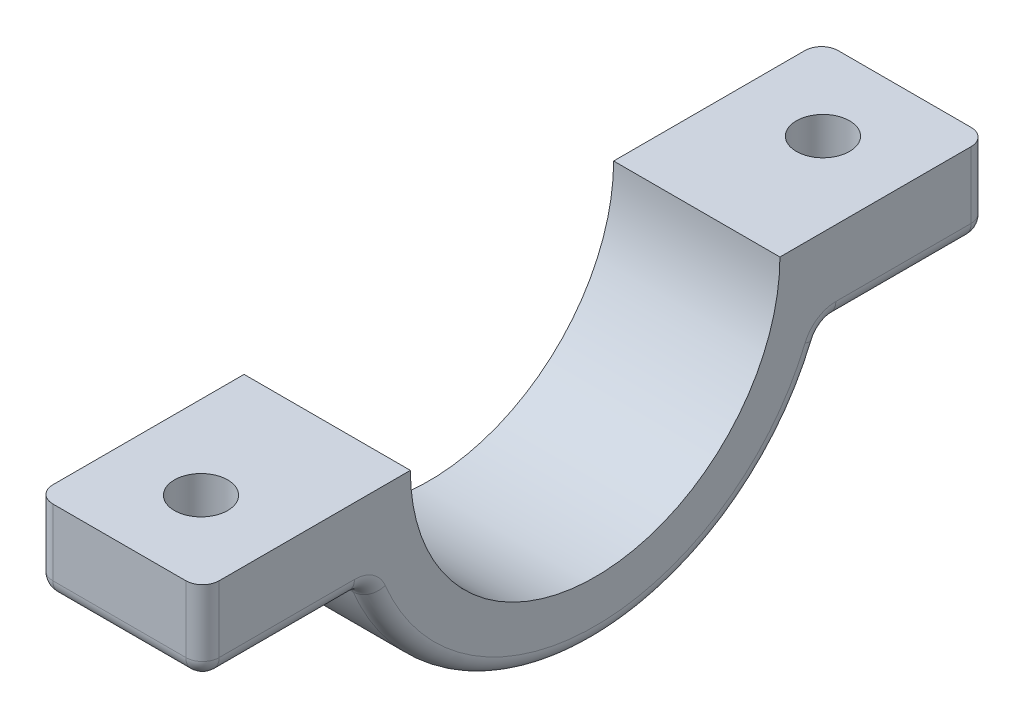
from build123d import *

# Parameters (mm, degrees)
CLAMP_EXTRUDE_DEPTH     = 10
HOLE_R                  = 1.6
HOLES_CUT_EXTRUDE_DEPTH = 6
FILLET1_R               = 1


with BuildPart() as part:
    # Sketch4 → Clamp Extrude (new body)
    with BuildSketch(Plane(origin=(0, 0, 0), x_dir=(0, 0, -1), z_dir=(1, 0, 0))):
        with BuildLine():
            Line((-23.6125, 0), (-11.1125, 0))
            ThreePointArc((-11.1125, 0), (0, -11.1125), (11.1125, 0))
            Line((11.1125, 0), (23.6125, 0))
            Line((23.6125, 0), (23.6125, -5))
            Line((23.6125, -5), (13.789947652, -5))
            ThreePointArc((13.789947652, -5), (0, -14.668423782), (-13.789947652, -5))
            Line((-13.789947652, -5), (-23.6125, -5))
            Line((-23.6125, -5), (-23.6125, 0))
        make_face()
    extrude(amount=CLAMP_EXTRUDE_DEPTH)

    # Hole → Holes Cut-Extrude (cut, through all)
    with BuildSketch(Plane.XZ.offset(5)):
        with Locations((5, 18.701223826)):
            Circle(HOLE_R)
        with Locations((5, -18.701223826)):
            Circle(HOLE_R)
    extrude(amount=-HOLES_CUT_EXTRUDE_DEPTH, mode=Mode.SUBTRACT)

    # Fillet1
    fillet1_edges = [part.edges().sort_by_distance(p)[0] for p in [
        (0, -2.5, -23.6125),
        (0, -5, -18.701223826),
        (0, -14.668423782, 0),
        (10, -2.5, -23.6125),
        (5, -5, 13.789947652),
        (5, -5, 23.6125),
        (5, -5, -23.6125),
        (5, -5, -13.789947652),
        (10, -2.5, 23.6125),
        (10, -5, 18.701223826),
        (10, -14.668423782, 0),
        (0, -5, 18.701223826),
        (10, -5, -18.701223826),
        (0, -2.5, 23.6125),
    ]]
    fillet(fillet1_edges, radius=FILLET1_R)


solid = part.part
